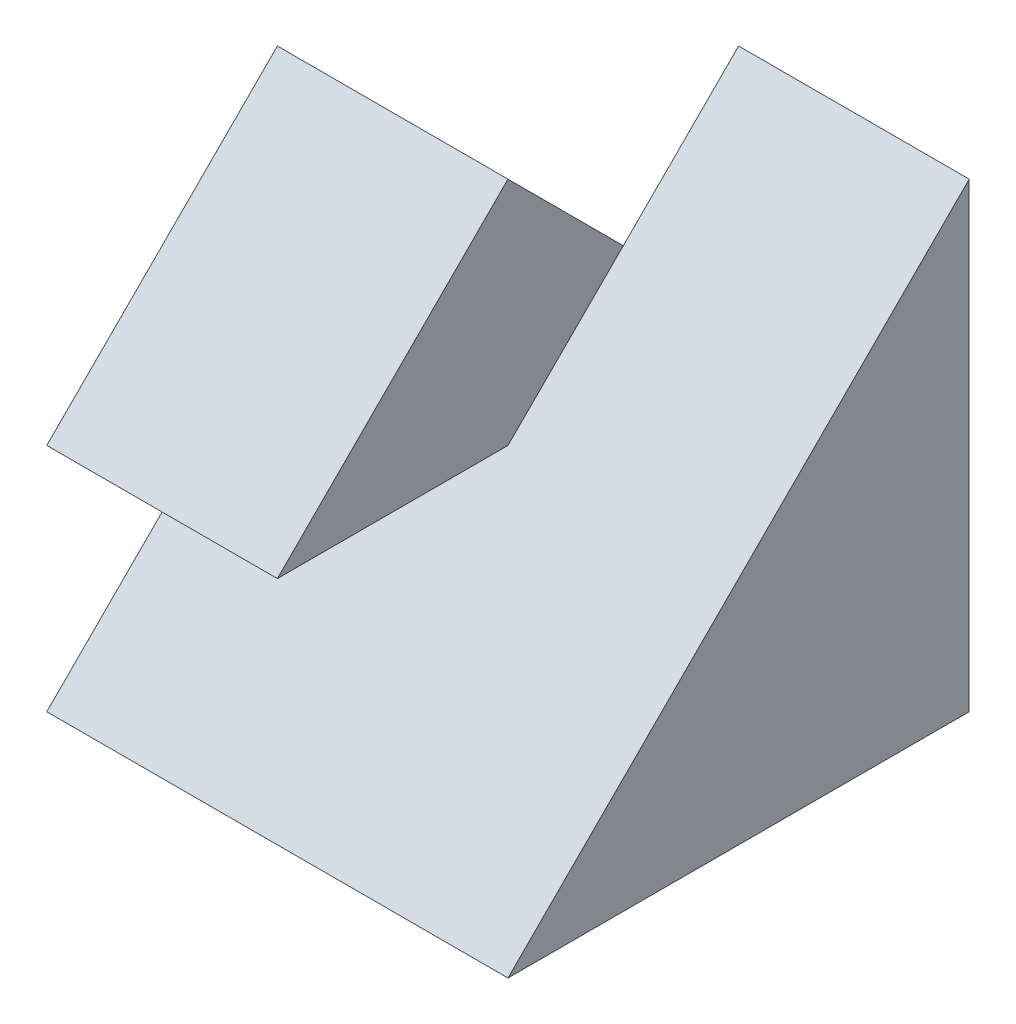
from build123d import *

# Parameters (mm, degrees)
SKETCH1_W           = 4
SKETCH1_H           = 4
BOSS_EXTRUDE1_DEPTH = 4
CUT_EXTRUDE1_DEPTH  = 2
CUT_EXTRUDE2_DEPTH  = 2


with BuildPart() as part:
    # Sketch1 → Boss-Extrude1 (new body)
    with BuildSketch(Plane(origin=(0, 0, 0), x_dir=(1, 0, 0), z_dir=(0, 1, 0))):
        Rectangle(SKETCH1_W, SKETCH1_H)
    extrude(amount=BOSS_EXTRUDE1_DEPTH)

    # Sketch2 → Cut-Extrude1 (cut)
    with BuildSketch(Plane.ZY.offset(2)):
        Polygon((0, 2), (2, 0), (2, 2), align=None)
        Polygon((0, 4), (2, 2), (2, 4), align=None)
        Polygon((0, 4), (-2, 2), (-2, 4), align=None)
    extrude(amount=-CUT_EXTRUDE1_DEPTH, mode=Mode.SUBTRACT)

    # Sketch3 → Cut-Extrude2 (cut)
    with BuildSketch(Plane(origin=(2, 0, 0), x_dir=(0, 0, -1), z_dir=(1, 0, 0))):
        Polygon((-2, 0), (2, 4), (-2, 4.116557223), align=None)
    extrude(amount=-CUT_EXTRUDE2_DEPTH, mode=Mode.SUBTRACT)


solid = part.part
